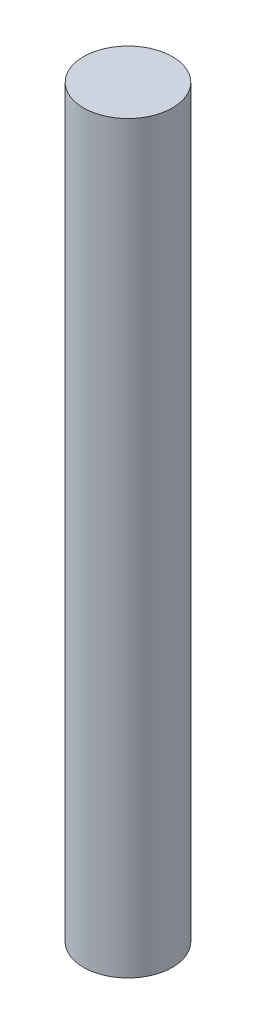
from build123d import *

# Parameters (mm, degrees)
SKETCH1_R           = 8
BOSS_EXTRUDE1_DEPTH = 134


with BuildPart() as part:
    # Sketch1 → Boss-Extrude1 (new body)
    with BuildSketch(Plane(origin=(0, 0, 0), x_dir=(1, 0, 0), z_dir=(0, 1, 0))):
        Circle(SKETCH1_R)
    extrude(amount=BOSS_EXTRUDE1_DEPTH)


solid = part.part
